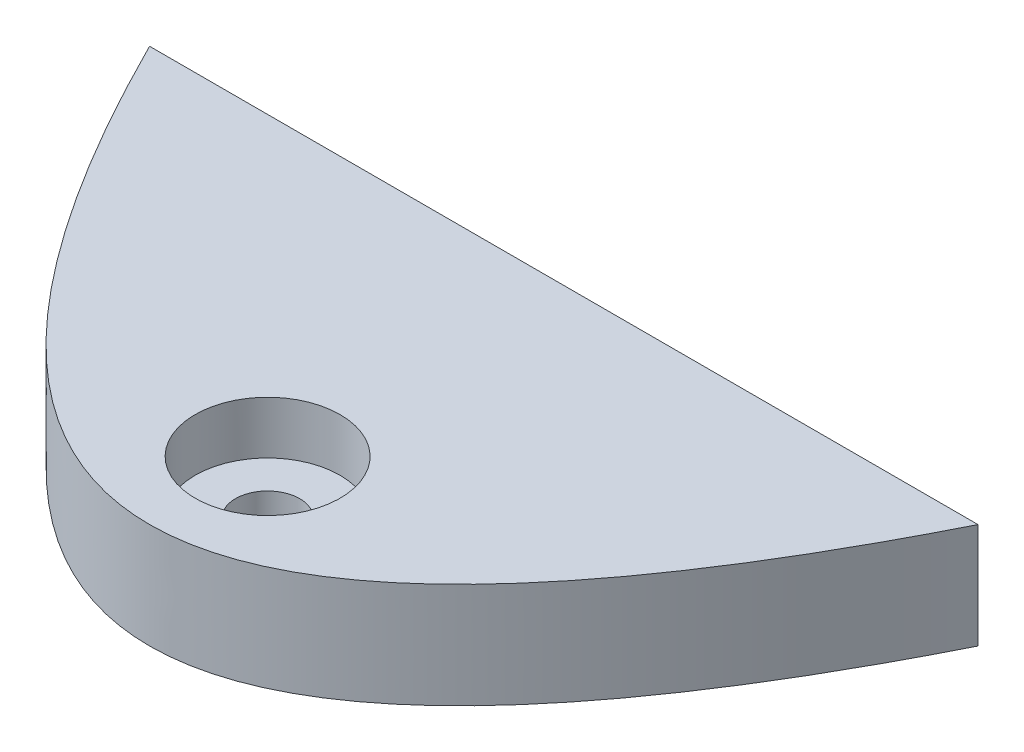
from build123d import *

# Parameters (mm, degrees)
BOSS_EXTRUDE1_DEPTH     = 300
SKETCH3_R               = 15.5
CUT_EXTRUDE1_DEPTH      = 23
CUT_EXTRUDE1_DEPTH_BACK = 23
SKETCH4_R               = 35
CUT_EXTRUDE3_DEPTH      = 300
SKETCH5_W               = 541.558659161
SKETCH5_H               = 211.066516127
SKETCH5_W_2             = 529.372370701
SKETCH5_H_2             = 106.264435371
CUT_EXTRUDE4_DEPTH      = 201.0000001


with BuildPart() as part:
    # Sketch1 → Boss-Extrude1 (new body)
    with BuildSketch(Plane(origin=(0, 0, 0), x_dir=(1, 0, 0), z_dir=(0, 1, 0))):
        with BuildLine():
            Line((-200, 1e-09), (200, 1e-09))
            add(Edge.make_bspline(
                [(-200, 1e-09), (0, -400.000000001), (200, 1e-09)],
                knots=[0.056028396, 0.056028396, 0.056028396, 0.943971604, 0.943971604, 0.943971604], degree=2))
        make_face()
    extrude(amount=BOSS_EXTRUDE1_DEPTH)

    # Sketch3 → Cut-Extrude1 (cut, two sides)
    with BuildSketch(Plane(origin=(0, 150, 0), x_dir=(1, 0, 0), z_dir=(0, 1, 0))) as cut_extrude1_sk:
        with Locations((0, -142.999999999)):
            Circle(SKETCH3_R)
    extrude(amount=CUT_EXTRUDE1_DEPTH, mode=Mode.SUBTRACT)
    extrude(cut_extrude1_sk.sketch, amount=-CUT_EXTRUDE1_DEPTH_BACK, mode=Mode.SUBTRACT)

    # Sketch4 → Cut-Extrude3 (cut)
    with BuildSketch(Plane(origin=(0, 173, 0), x_dir=(1, 0, 0), z_dir=(0, 1, 0))):
        with Locations((0, -142.999999999)):
            Circle(SKETCH4_R)
    cut_extrude3 = extrude(amount=CUT_EXTRUDE3_DEPTH, mode=Mode.SUBTRACT)

    # Mirror1: Cut-Extrude3 across plane
    add(cut_extrude3.mirror(Plane.ZX.offset(150)), mode=Mode.SUBTRACT)

    # Sketch5 → Cut-Extrude4 (cut, through all)
    with BuildSketch(Plane(origin=(0, 0, 0), x_dir=(-1, 0, 0), z_dir=(0, 0, -1))):
        with Locations((21.44786769, 42.066741937)):
            Rectangle(SKETCH5_W, SKETCH5_H)
        with Locations((2.680983461, 251.532217686)):
            Rectangle(SKETCH5_W_2, SKETCH5_H_2)
    extrude(amount=-CUT_EXTRUDE4_DEPTH, mode=Mode.SUBTRACT)


solid = part.part
